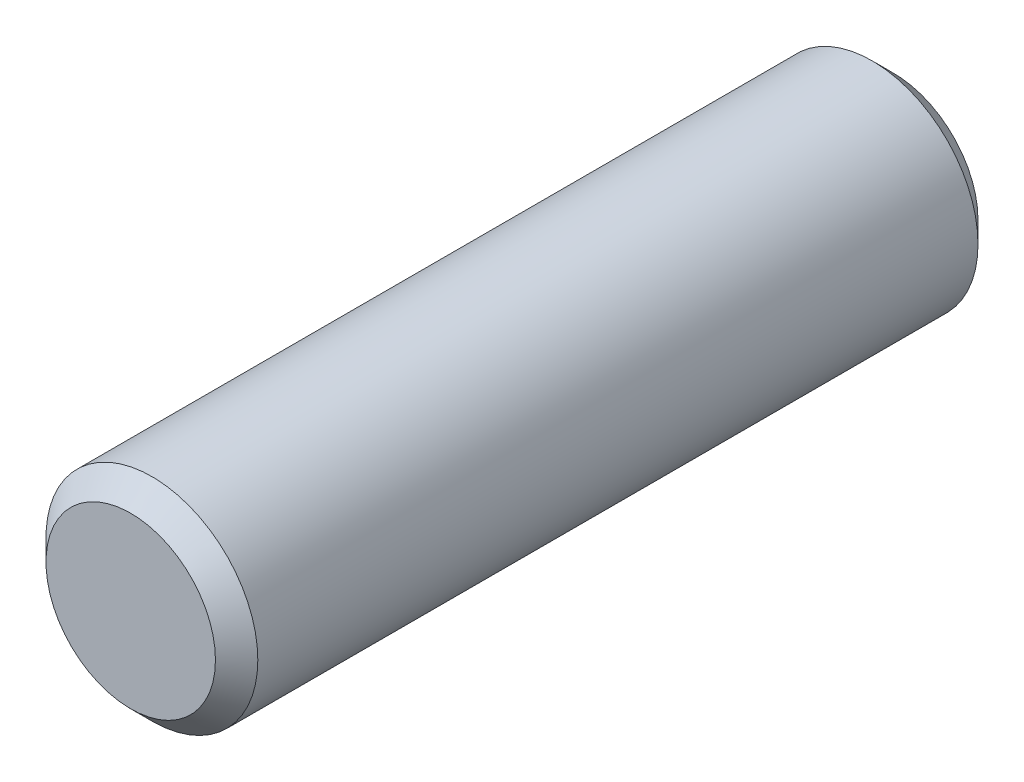
from build123d import *

# Parameters (mm, degrees)
SKETCH2_R           = 5
BOSS_EXTRUDE1_DEPTH = 36
CHAMFER1_SIZE       = 1


with BuildPart() as part:
    # Sketch2 → Boss-Extrude1 (new body)
    with BuildSketch(Plane.XY):
        Circle(SKETCH2_R)
    extrude(amount=BOSS_EXTRUDE1_DEPTH)

    # Chamfer1
    chamfer1_edges = [part.edges().sort_by_distance(p)[0] for p in [
        (-5, 0, 0),
        (-5, 0, 36),
    ]]
    chamfer(chamfer1_edges, length=CHAMFER1_SIZE)


solid = part.part
